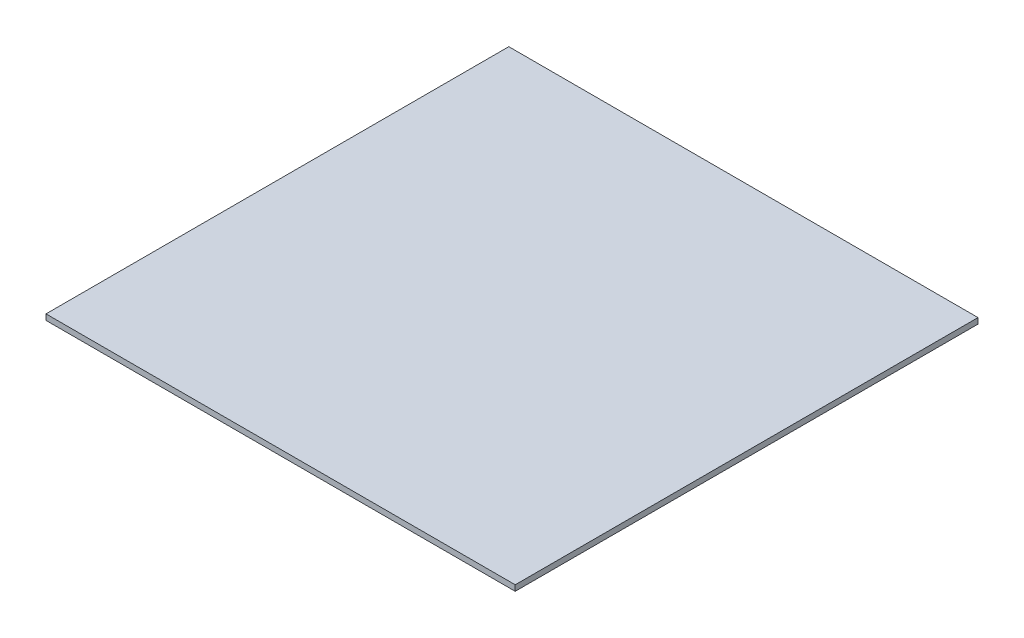
from build123d import *

# Parameters (mm, degrees)
SKETCH1_W           = 984.25
SKETCH1_H           = 970.788
BOSS_EXTRUDE1_DEPTH = 11.938


with BuildPart() as part:
    # Sketch1 → Boss-Extrude1 (new body)
    with BuildSketch(Plane(origin=(0, 0, 0), x_dir=(1, 0, 0), z_dir=(0, 1, 0))):
        Rectangle(SKETCH1_W, SKETCH1_H)
    extrude(amount=BOSS_EXTRUDE1_DEPTH)


solid = part.part
